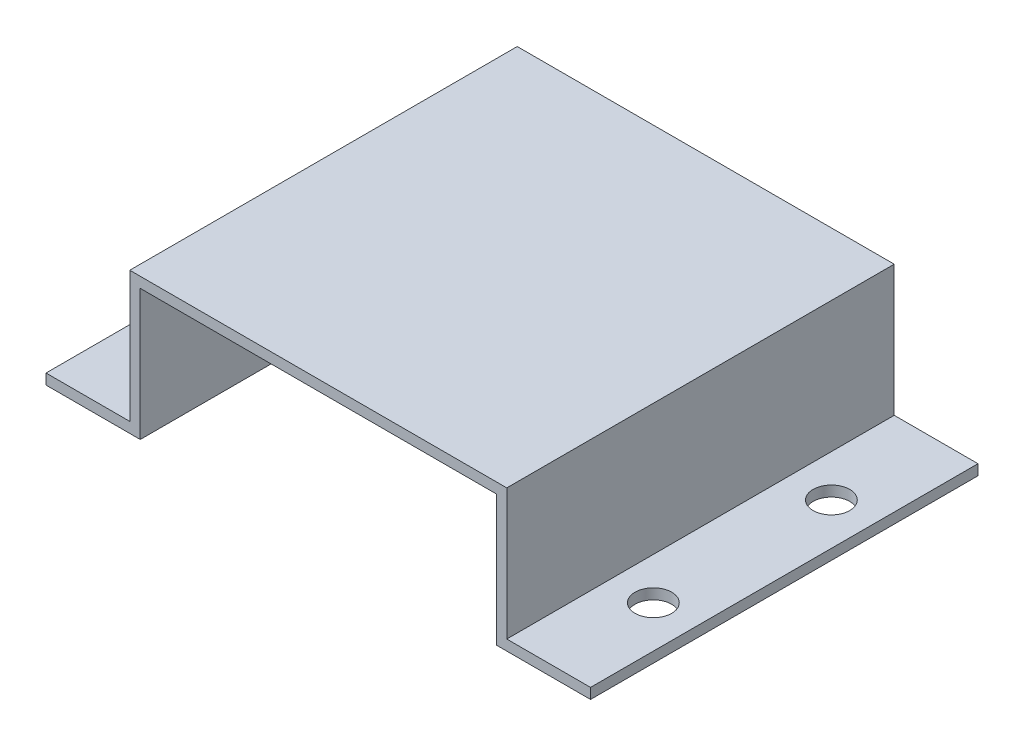
from build123d import *

# Parameters (mm, degrees)
BOSS_EXTRUDE1_DEPTH = 37
SKETCH2_R           = 1.75
CUT_EXTRUDE1_DEPTH  = 6


with BuildPart() as part:
    # Sketch1 → Boss-Extrude1 (new body)
    with BuildSketch(Plane.XY):
        Polygon((1, 11.5), (35, 11.5), (35, -1), (44, -1), (44, 0), (36, 0), (36, 12.5), (0, 12.5), (0, 0), (-8, 0), (-8, -1), (1, -1), align=None)
    extrude(amount=BOSS_EXTRUDE1_DEPTH)

    # Sketch2 → Cut-Extrude1 (cut)
    with BuildSketch(Plane(origin=(0, 0, 0), x_dir=(1, 0, 0), z_dir=(0, 1, 0))):
        with Locations((-4, -27)):
            Circle(SKETCH2_R)
        with Locations((-4, -10)):
            Circle(SKETCH2_R)
        with Locations((40, -27)):
            Circle(SKETCH2_R)
        with Locations((40, -10)):
            Circle(SKETCH2_R)
    extrude(amount=-CUT_EXTRUDE1_DEPTH, mode=Mode.SUBTRACT)


solid = part.part
